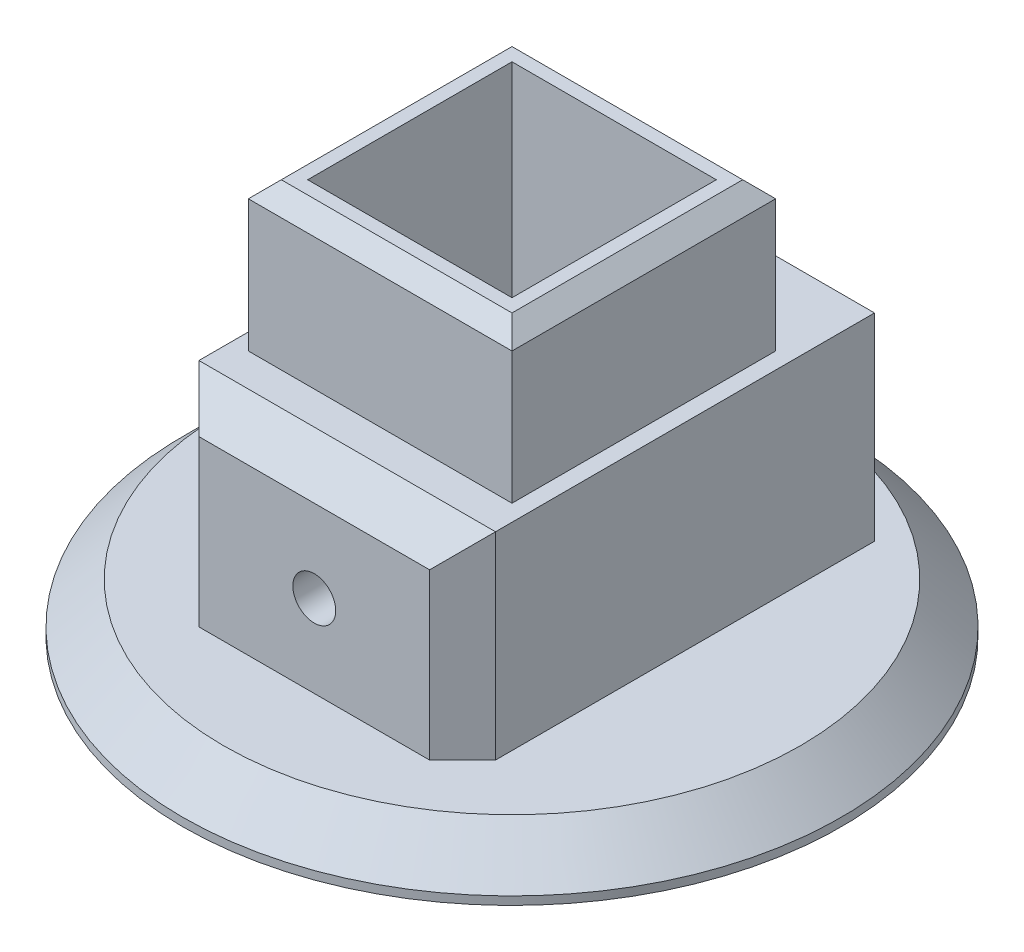
from build123d import *

# Parameters (mm, degrees)
SKETCH1_W               = 16
SKETCH1_H               = 16
BOSS_EXTRUDE1_DEPTH     = 24
SKETCH12_W              = 12.4
SKETCH12_H              = 12.4
CUT_EXTRUDE6_DEPTH      = 22
SKETCH13_R              = 20
BOSS_EXTRUDE2_DEPTH     = 3
CHAMFER1_SIZE           = 2.5
SKETCH14_W              = 16
SKETCH14_H              = 16
BOSS_EXTRUDE3_DEPTH     = 12
CUT_EXTRUDE1_DEPTH      = 7.5
SKETCH11_W              = 4.2
SKETCH11_H              = 5.5
CUT_EXTRUDE5_DEPTH      = 6.3
CUT_EXTRUDE5_DEPTH_BACK = 0.1
CHAMFER2_SIZE           = 2
CHAMFER4_SIZE           = 2
SKETCH15_R              = 1.3
CUT_EXTRUDE7_DEPTH      = 28.5
CHAMFER5_SIZE           = 1


with BuildPart() as part:
    # Sketch1 → Boss-Extrude1 (new body)
    with BuildSketch(Plane(origin=(0, 0, 0), x_dir=(1, 0, 0), z_dir=(0, 1, 0))):
        with Locations((0, 8)):
            Rectangle(SKETCH1_W, SKETCH1_H)
    extrude(amount=BOSS_EXTRUDE1_DEPTH)

    # Sketch12 → Cut-Extrude6 (cut)
    with BuildSketch(Plane(origin=(0, 24, 0), x_dir=(1, 0, 0), z_dir=(0, 1, 0))):
        with Locations((0, 8)):
            Rectangle(SKETCH12_W, SKETCH12_H)
    extrude(amount=-CUT_EXTRUDE6_DEPTH, mode=Mode.SUBTRACT)

    # Sketch13 → Boss-Extrude2 (add)
    with BuildSketch(Plane(origin=(0, 0, 0), x_dir=(1, 0, 0), z_dir=(0, 1, 0))):
        with Locations((0, 8)):
            Circle(SKETCH13_R)
    extrude(amount=BOSS_EXTRUDE2_DEPTH)

    # Chamfer1
    chamfer1_edges = [part.edges().sort_by_distance(p)[0] for p in [
        (-20, 3, -8),
    ]]
    chamfer(chamfer1_edges, length=CHAMFER1_SIZE)

    # Sketch14 → Boss-Extrude3 (add)
    with BuildSketch(Plane(origin=(0, 3, 0), x_dir=(1, 0, 0), z_dir=(0, 1, 0))):
        Polygon((-8, 23), (8, 23), (9, 23), (9, -4), (8, -4), (-8, -4), (-9, -4), (-9, 23), align=None)
        with Locations((0, 8)):
            Rectangle(SKETCH14_W, SKETCH14_H, mode=Mode.SUBTRACT)
    extrude(amount=BOSS_EXTRUDE3_DEPTH)

    # Sketch5 → Cut-Extrude1 (cut)
    with BuildSketch(Plane(origin=(0, 0, -23), x_dir=(-1, 0, 0), z_dir=(0, 0, -1))):
        with BuildLine():
            Line((-2.1, 11.1), (2.1, 11.1))
            Line((2.1, 11.1), (3.1, 10.1))
            Line((3.1, 10.1), (3.1, 8.8))
            ThreePointArc((3.1, 8.8), (3.9, 8), (3.1, 7.2))
            Line((3.1, 7.2), (3.1, 4.9))
            Line((3.1, 4.9), (-3.1, 4.9))
            Line((-3.1, 4.9), (-3.1, 7.2))
            ThreePointArc((-3.1, 7.2), (-3.9, 8), (-3.1, 8.8))
            Line((-3.1, 8.8), (-3.1, 10.1))
            Line((-3.1, 10.1), (-2.1, 11.1))
        make_face()
    extrude(amount=-CUT_EXTRUDE1_DEPTH, mode=Mode.SUBTRACT)

    # Sketch11 → Cut-Extrude5 (cut, two sides)
    with BuildSketch(Plane.XZ.offset(-11.1)) as cut_extrude5_sk:
        with Locations((0, -18.25)):
            Rectangle(SKETCH11_W, SKETCH11_H)
    extrude(amount=CUT_EXTRUDE5_DEPTH, mode=Mode.SUBTRACT)
    extrude(cut_extrude5_sk.sketch, amount=-CUT_EXTRUDE5_DEPTH_BACK, mode=Mode.SUBTRACT)

    # Chamfer2
    chamfer2_edges = [part.edges().sort_by_distance(p)[0] for p in [
        (0, 15, -23),
        (9, 9, -23),
        (-9, 9, -23),
    ]]
    chamfer(chamfer2_edges, length=CHAMFER2_SIZE)

    # Chamfer4
    chamfer4_edges = [part.edges().sort_by_distance(p)[0] for p in [
        (0, 15, 4),
        (-9, 9, 4),
        (9, 9, 4),
    ]]
    chamfer(chamfer4_edges, length=CHAMFER4_SIZE)

    # Sketch15 → Cut-Extrude7 (cut, through all)
    with BuildSketch(Plane(origin=(0, 0, -15.5), x_dir=(-1, 0, 0), z_dir=(0, 0, -1))):
        with Locations((0, 8)):
            Circle(SKETCH15_R)
    extrude(amount=-CUT_EXTRUDE7_DEPTH, mode=Mode.SUBTRACT)

    # Chamfer5
    chamfer5_edges = [part.edges().sort_by_distance(p)[0] for p in [
        (0, 24, -16),
        (-8, 24, -8),
        (0, 24, 0),
        (8, 24, -8),
    ]]
    chamfer(chamfer5_edges, length=CHAMFER5_SIZE)


solid = part.part
